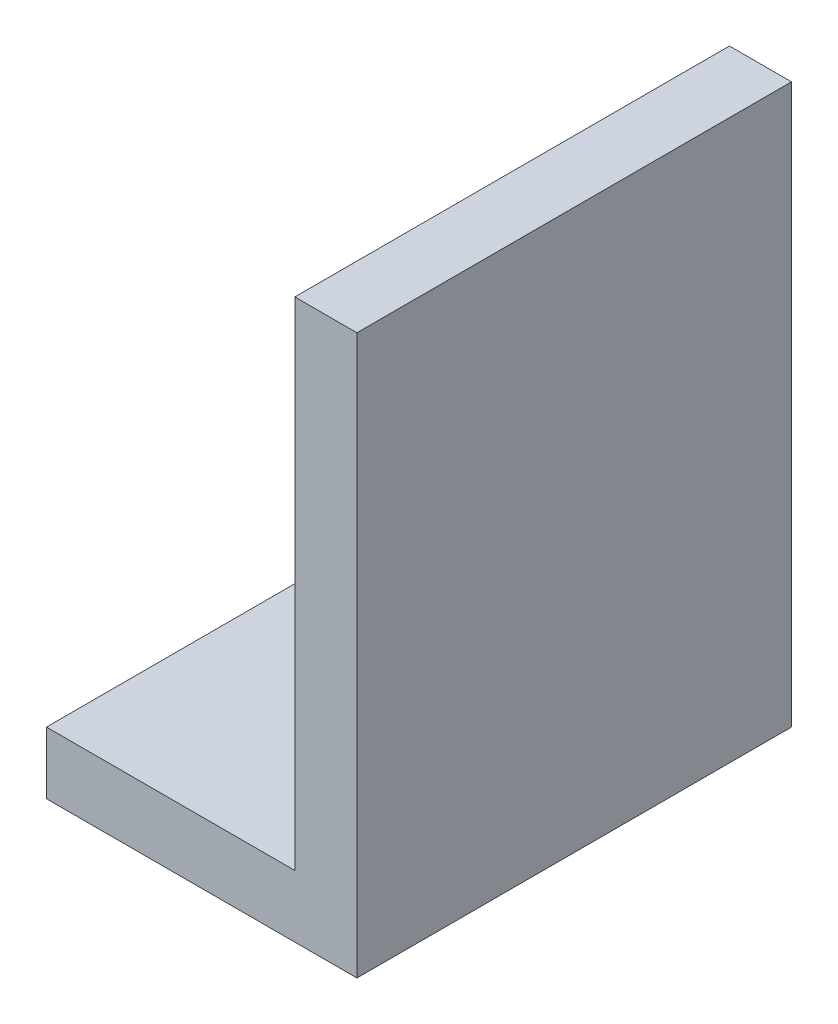
from build123d import *

# Parameters (mm, degrees)
BOSS_EXTRUDE1_DEPTH = 70


with BuildPart() as part:
    # Sketch1 → Boss-Extrude1 (new body)
    with BuildSketch(Plane.XY):
        Polygon((0, 0), (50, 0), (50, 90), (40, 90), (40, 10), (0, 10), align=None)
    extrude(amount=BOSS_EXTRUDE1_DEPTH)


solid = part.part
